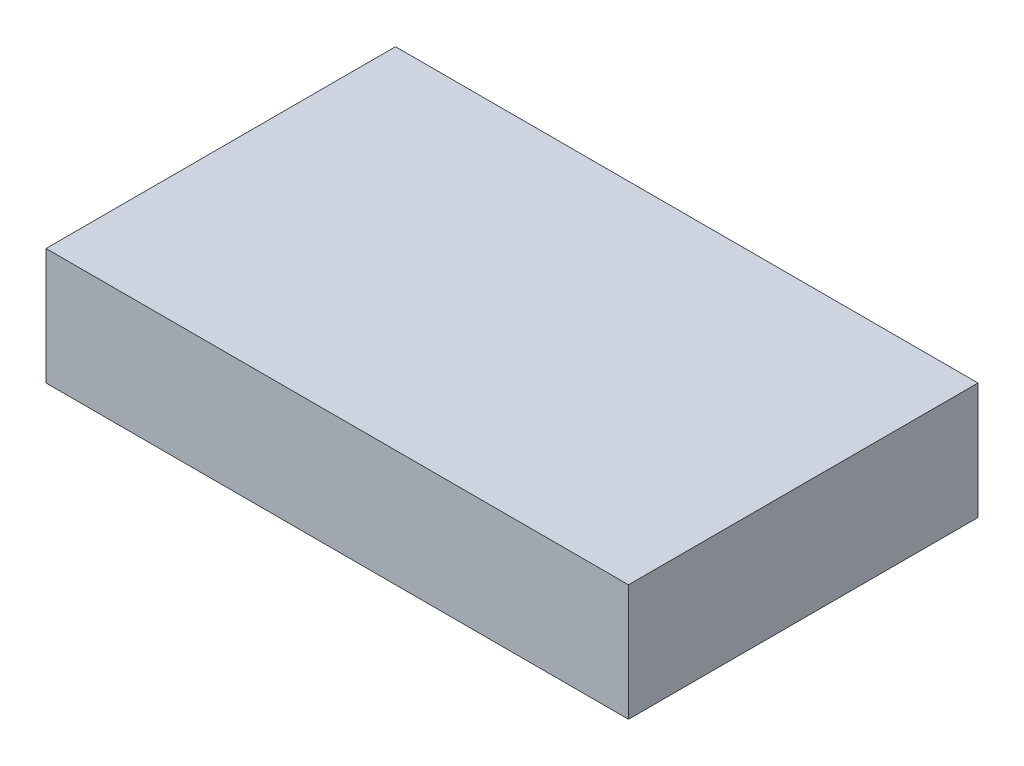
from build123d import *

# Parameters (mm, degrees)
SKETCH_1_W      = 250
SKETCH_1_H      = 150
EXTRUDE_1_DEPTH = 50


with BuildPart() as part:
    # 草图1 → 凸台-拉伸1 (new body)
    with BuildSketch(Plane(origin=(0, 0, 0), x_dir=(1, 0, 0), z_dir=(0, 1, 0))):
        Rectangle(SKETCH_1_W, SKETCH_1_H)
    extrude(amount=EXTRUDE_1_DEPTH)


solid = part.part
